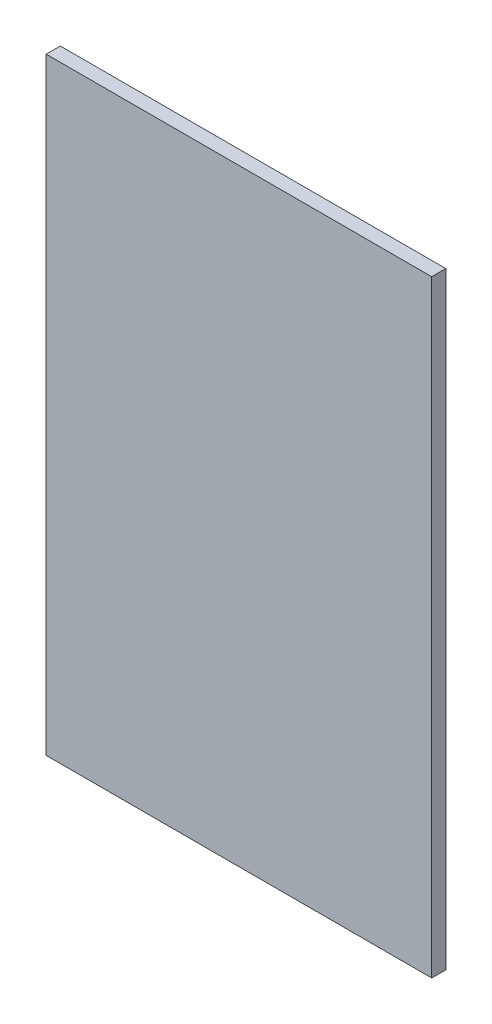
from build123d import *

# Parameters (mm, degrees)
SKETCH2_W           = 82
SKETCH2_H           = 129.170430053
BOSS_EXTRUDE1_DEPTH = 3


with BuildPart() as part:
    # Sketch2 → Boss-Extrude1 (new body)
    with BuildSketch(Plane.XY):
        with Locations((105.048780488, 12.780336978)):
            Rectangle(SKETCH2_W, SKETCH2_H)
    extrude(amount=BOSS_EXTRUDE1_DEPTH)


solid = part.part
